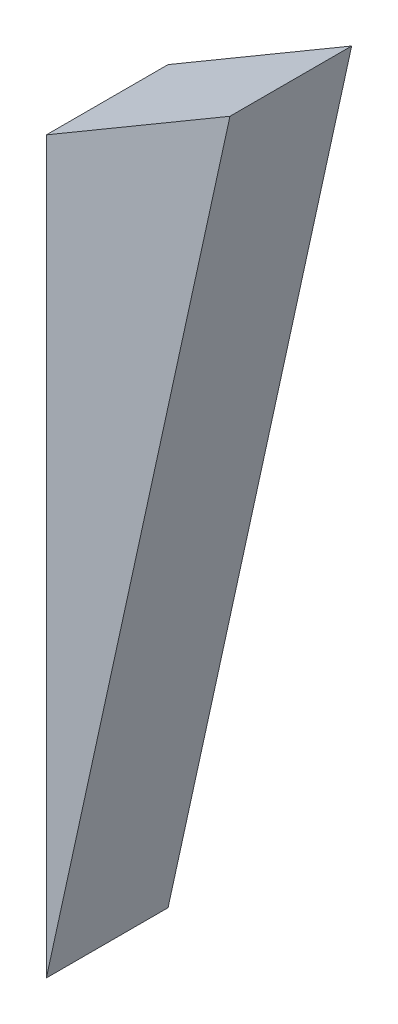
from build123d import *

# Parameters (mm, degrees)
BOSS_EXTRUDE1_DEPTH = 2


with BuildPart() as part:
    # Sketch1 → Boss-Extrude1 (new body)
    with BuildSketch(Plane.XY):
        Polygon((0, 0), (0, -12), (3.017497123, 1.773333333), align=None)
    extrude(amount=BOSS_EXTRUDE1_DEPTH)


solid = part.part
